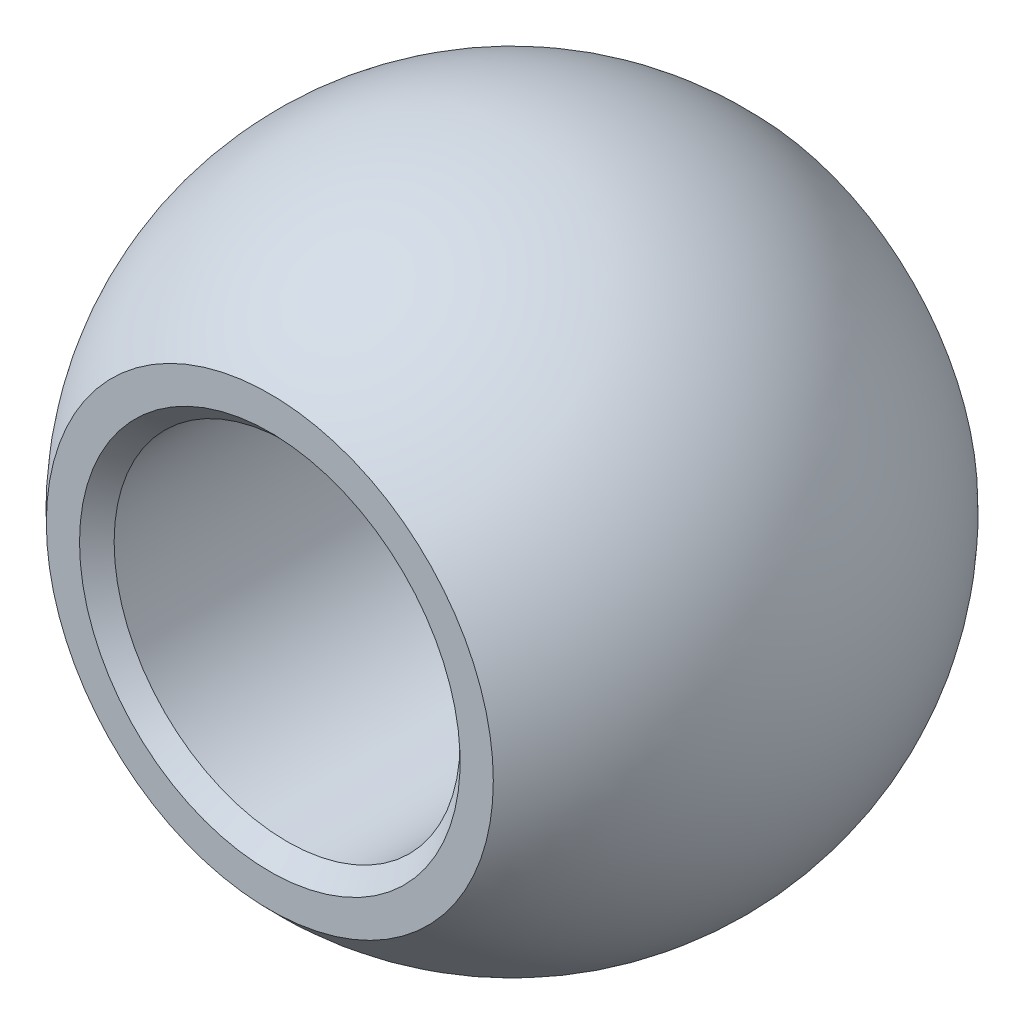
from build123d import *

# Parameters (mm, degrees)
CUT_EXTRUDE1_DEPTH      = 17.497783942093555
CUT_EXTRUDE1_DEPTH_BACK = 17.497783942093555
SKETCH2_W               = 2.524999999999989
SKETCH2_H               = 19.05
SKETCH2_W_2             = 2.5249999999999906
SKETCH2_H_2             = 19.049999999999997
CUT_EXTRUDE2_DEPTH      = 17.497783942093555
CUT_EXTRUDE2_DEPTH_BACK = 17.497783942093555
SKETCH3_R               = 5
CHAMFER1_SIZE           = 0.5


with BuildPart() as part:
    # Sketch1 → Revolve1 (revolve)
    with BuildSketch(Plane.XY):
        with BuildLine():
            Line((3.5e-15, 9.525), (3.5e-15, -9.525))
            ThreePointArc((3.5e-15, -9.525), (9.525, 0), (3.5e-15, 9.525))
        make_face()
    revolve(axis=Axis((3.5e-15, 9.525, 0), (0, -1, 0)))

    # Sketch2 → Cut-Extrude1 (cut, two sides: drawn at the far end of the back side and taken through both)
    with BuildSketch(Plane(origin=(0, 0, 0), x_dir=(0, 0, -1), z_dir=(1, 0, 0)).offset(-CUT_EXTRUDE1_DEPTH_BACK)):
        with Locations((8.262499999999998, 0)):
            Rectangle(SKETCH2_W, SKETCH2_H)
        with Locations((-8.2625, 0)):
            Rectangle(SKETCH2_W_2, SKETCH2_H_2)
    extrude(amount=CUT_EXTRUDE1_DEPTH + CUT_EXTRUDE1_DEPTH_BACK, mode=Mode.SUBTRACT)

    # Sketch3 → Cut-Extrude2 (cut, two sides: drawn at the far end of the back side and taken through both)
    with BuildSketch(Plane.XY.offset(-CUT_EXTRUDE2_DEPTH_BACK)):
        Circle(SKETCH3_R)
    extrude(amount=CUT_EXTRUDE2_DEPTH + CUT_EXTRUDE2_DEPTH_BACK, mode=Mode.SUBTRACT)

    # Chamfer1
    chamfer1_edges = [part.edges().sort_by_distance(p)[0] for p in [
        (-5, 6.1e-16, -7.000000000000003),
        (-5, -6.1e-16, 7.000000000000004),
    ]]
    chamfer(chamfer1_edges, length=CHAMFER1_SIZE)


solid = part.part
